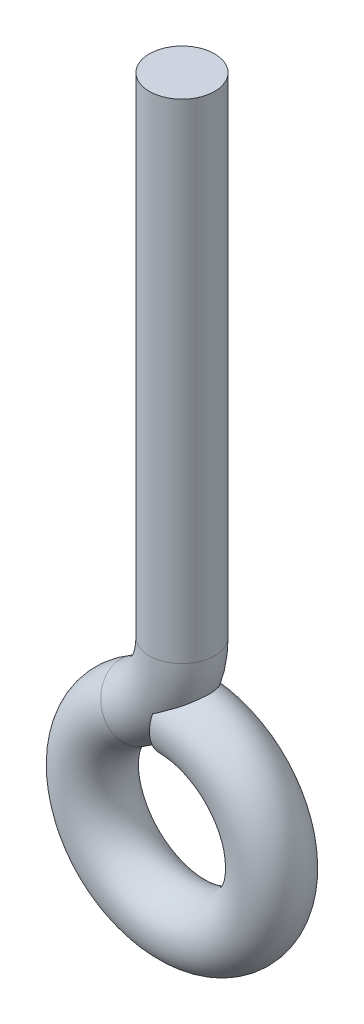
from build123d import *

# Parameters (mm, degrees)
SKETCH2_R = 2


with BuildPart() as part:
    # Sweep1: sweep along a path in Sketch1
    with BuildLine(Plane.XY) as sweep1_path:
        Line((0, 39.526279442), (0, 9.526279442))
        ThreePointArc((0, 9.526279442), (-0.736860279, 6.776279442), (-2.75, 4.763139721))
        ThreePointArc((-2.75, 4.763139721), (1.423504748, -5.312592045), (0, 5.5))
    # Sketch2 → Sweep1 (sweep)
    with BuildSketch(Plane(origin=(0, 39.526279442, 0), x_dir=(1, 0, 0), z_dir=(0, 1, 0))):
        Circle(SKETCH2_R)
    sweep(path=sweep1_path.line)


solid = part.part
